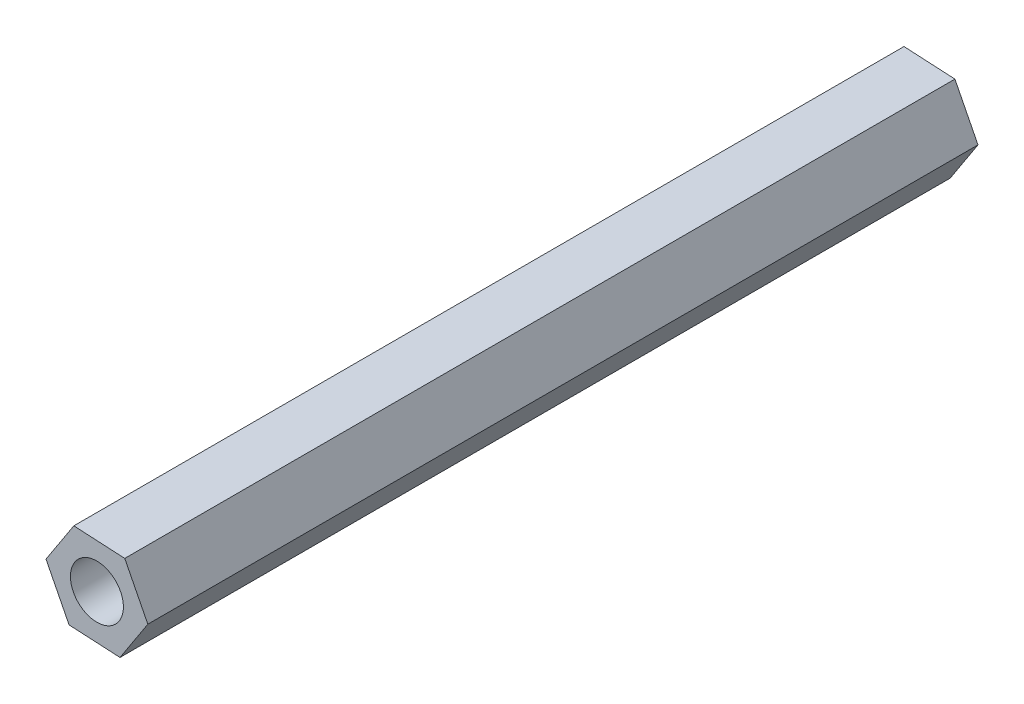
from build123d import *

# Parameters (mm, degrees)
BOSS_EXTRUDE1_DEPTH = 47
SKETCH2_R           = 1.5
CUT_EXTRUDE1_DEPTH  = 48


with BuildPart() as part:
    # Sketch1 → Boss-Extrude1 (new body)
    with BuildSketch(Plane.XY):
        Polygon((1.57545706, 2.418939517), (-1.307134542, 2.573855595), (-2.882591602, 0.154916078), (-1.57545706, -2.418939517), (1.307134542, -2.573855595), (2.882591602, -0.154916078), align=None)
    extrude(amount=BOSS_EXTRUDE1_DEPTH)

    # Sketch2 → Cut-Extrude1 (cut, through all)
    with BuildSketch(Plane(origin=(0, 0, 0), x_dir=(-1, 0, 0), z_dir=(0, 0, -1))):
        Circle(SKETCH2_R)
    extrude(amount=-CUT_EXTRUDE1_DEPTH, mode=Mode.SUBTRACT)


solid = part.part
